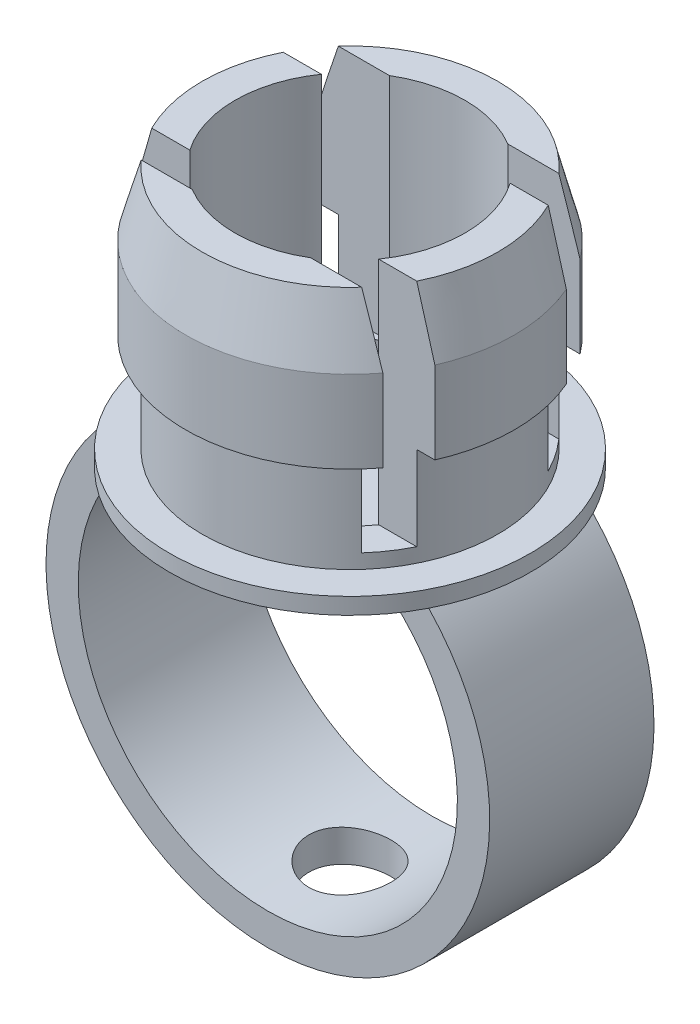
from build123d import *

# Parameters (mm, degrees)
CROQUIS2_W              = 26
CROQUIS2_H              = 2
CORTAR_EXTRUIR1_DEPTH   = 14
CROQUIS3_W              = 27
CROQUIS3_H              = 10
SALIENTE_EXTRUIR1_DEPTH = 24
CORTAR_EXTRUIR2_DEPTH   = 10
CROQUIS5_R              = 1.5
CORTAR_EXTRUIR3_DEPTH   = 24
CROQUIS6_R              = 2.5
CORTAR_EXTRUIR4_DEPTH   = 24


with BuildPart() as part:
    # Croquis1 → Revolución1 (revolve)
    with BuildSketch(Plane.XY):
        Polygon((-89.778094977, -14.637996222), (-78.782252338, -14.637996222), (-78.782252338, -13.637996222), (-85.782252338, -13.637996222), (-85.782252338, 1.235955759), (-87.782252338, 1.235955759), (-88.782252338, -2.637996222), (-88.782252338, -7.637996222), (-87.782252338, -7.637996222), (-87.782252338, -13.637996222), (-89.778094977, -13.637996222), align=None)
    revolve(axis=Axis((-78.782252338, -14.637996222, 0), (0, 1, 0)))

    # Croquis2 → Cortar-Extruir1 (cut)
    with BuildSketch(Plane(origin=(0, 1.235955759, 0), x_dir=(1, 0, 0), z_dir=(0, 1, 0))):
        with Locations((-78.782252338, -5)):
            Rectangle(CROQUIS2_W, CROQUIS2_H)
        with Locations((-78.782252338, 5)):
            Rectangle(CROQUIS2_W, CROQUIS2_H)
    extrude(amount=-CORTAR_EXTRUIR1_DEPTH, mode=Mode.SUBTRACT)

    # Croquis3 → Saliente-Extruir1 (add)
    with BuildSketch(Plane.XZ.offset(14.637996222)):
        with Locations((-78.782252338, 0)):
            Rectangle(CROQUIS3_W, CROQUIS3_H)
    extrude(amount=SALIENTE_EXTRUIR1_DEPTH)

    # Croquis4 → Cortar-Extruir2 (cut)
    with BuildSketch(Plane(origin=(0, 0, -5), x_dir=(-1, 0, 0), z_dir=(0, 0, -1))):
        with BuildLine():
            Line((92.282252338, -38.637996222), (92.282252338, -23.930005944))
            ThreePointArc((92.282252338, -23.930005944), (78.782252338, -37.430005944), (65.282252338, -23.930005944))
            Line((65.282252338, -23.930005944), (65.282252338, -38.637996222))
            Line((65.282252338, -38.637996222), (92.282252338, -38.637996222))
        make_face()
        with BuildLine():
            Line((92.282252338, -14.637996222), (88.575543682, -14.637996222))
            ThreePointArc((88.575543682, -14.637996222), (91.321379763, -18.927978012), (92.282252338, -23.930005944))
            Line((92.282252338, -23.930005944), (92.282252338, -14.637996222))
        make_face()
        with BuildLine():
            Line((65.282252338, -14.637996222), (65.282252338, -23.930005944))
            ThreePointArc((65.282252338, -23.930005944), (66.243124914, -18.927978012), (68.988960995, -14.637996222))
            Line((68.988960995, -14.637996222), (65.282252338, -14.637996222))
        make_face()
        with BuildLine():
            ThreePointArc((71.988960995, -14.637996222), (78.782252338, -35.498695349), (85.575543682, -14.637996222))
            Line((85.575543682, -14.637996222), (71.988960995, -14.637996222))
        make_face()
    extrude(amount=-CORTAR_EXTRUIR2_DEPTH, mode=Mode.SUBTRACT)

    # Croquis5 → Cortar-Extruir3 (cut)
    with BuildSketch(Plane(origin=(0, -13.637996222, 0), x_dir=(1, 0, 0), z_dir=(0, 1, 0))):
        with Locations((-78.782252338, 0)):
            Circle(CROQUIS5_R)
    extrude(amount=-CORTAR_EXTRUIR3_DEPTH, mode=Mode.SUBTRACT)

    # Croquis6 → Cortar-Extruir4 (cut)
    with BuildSketch(Plane.XZ.offset(14.637996222)):
        with Locations((-78.782252338, 0)):
            Circle(CROQUIS6_R)
    extrude(amount=CORTAR_EXTRUIR4_DEPTH, mode=Mode.SUBTRACT)


solid = part.part
